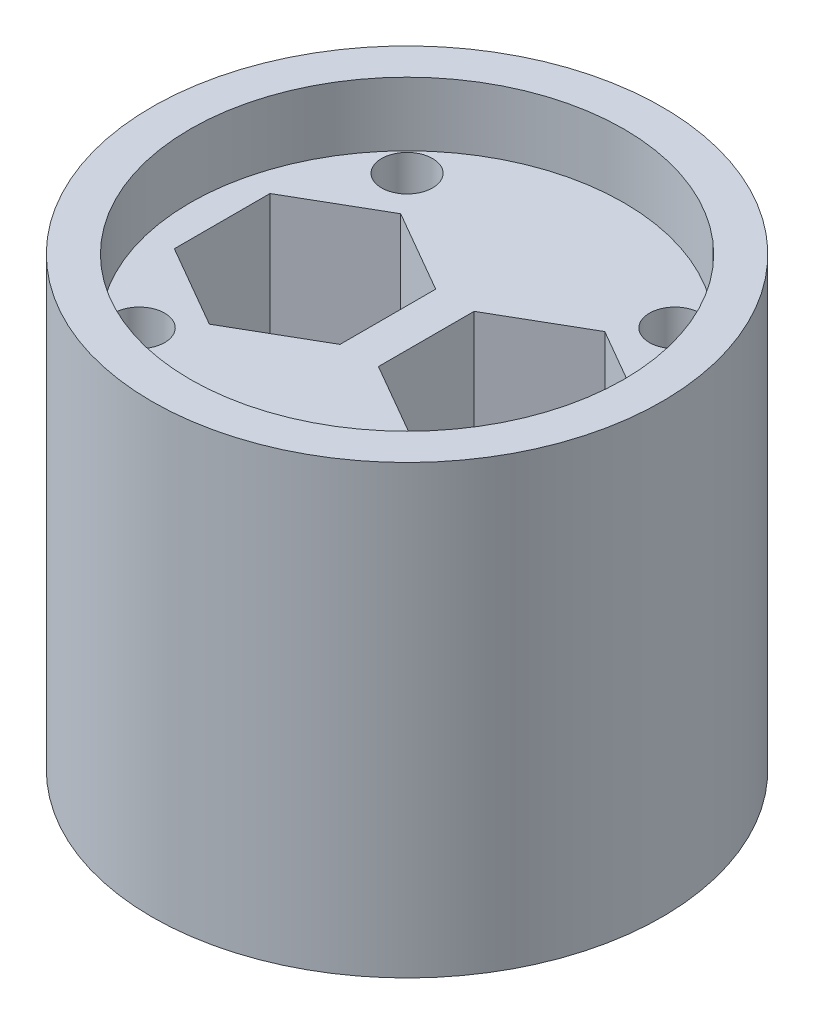
from build123d import *

# Parameters (mm, degrees)
SKETCH1_R           = 20
BOSS_EXTRUDE1_DEPTH = 35
CUT_EXTRUDE1_DEPTH  = 15
SKETCH3_R           = 4.1
CUT_EXTRUDE2_DEPTH  = 21
SKETCH4_R           = 2
CUT_EXTRUDE3_DEPTH  = 36
SKETCH5_R           = 17
CUT_EXTRUDE4_DEPTH  = 5


with BuildPart() as part:
    # Sketch1 → Boss-Extrude1 (new body)
    with BuildSketch(Plane(origin=(0, 0, 0), x_dir=(1, 0, 0), z_dir=(0, 1, 0))):
        Circle(SKETCH1_R)
    extrude(amount=BOSS_EXTRUDE1_DEPTH)

    # Sketch2 → Cut-Extrude1 (cut)
    with BuildSketch(Plane(origin=(0, 35, 0), x_dir=(1, 0, 0), z_dir=(0, 1, 0))):
        Polygon((-8, 7.5), (-14.495190528, 3.75), (-14.495190528, -3.75), (-8, -7.5), (-1.504809472, -3.75), (-1.504809472, 3.75), align=None)
        Polygon((8, 7.5), (1.504809472, 3.75), (1.504809472, -3.75), (8, -7.5), (14.495190528, -3.75), (14.495190528, 3.75), align=None)
    extrude(amount=-CUT_EXTRUDE1_DEPTH, mode=Mode.SUBTRACT)

    # Sketch3 → Cut-Extrude2 (cut, through all)
    with BuildSketch(Plane(origin=(0, 20, 0), x_dir=(1, 0, 0), z_dir=(0, 1, 0))):
        with Locations((-8, 0)):
            Circle(SKETCH3_R)
        with Locations((8, 0)):
            Circle(SKETCH3_R)
    extrude(amount=-CUT_EXTRUDE2_DEPTH, mode=Mode.SUBTRACT)

    # Sketch4 → Cut-Extrude3 (cut, through all)
    with BuildSketch(Plane(origin=(0, 35, 0), x_dir=(1, 0, 0), z_dir=(0, 1, 0))):
        with Locations((-10.5, 10.5)):
            Circle(SKETCH4_R)
        with Locations((10.5, 10.5)):
            Circle(SKETCH4_R)
        with Locations((10.5, -10.5)):
            Circle(SKETCH4_R)
        with Locations((-10.5, -10.5)):
            Circle(SKETCH4_R)
    extrude(amount=-CUT_EXTRUDE3_DEPTH, mode=Mode.SUBTRACT)

    # Sketch5 → Cut-Extrude4 (cut)
    with BuildSketch(Plane(origin=(0, 35, 0), x_dir=(1, 0, 0), z_dir=(0, 1, 0))):
        Circle(SKETCH5_R)
    extrude(amount=-CUT_EXTRUDE4_DEPTH, mode=Mode.SUBTRACT)


solid = part.part
